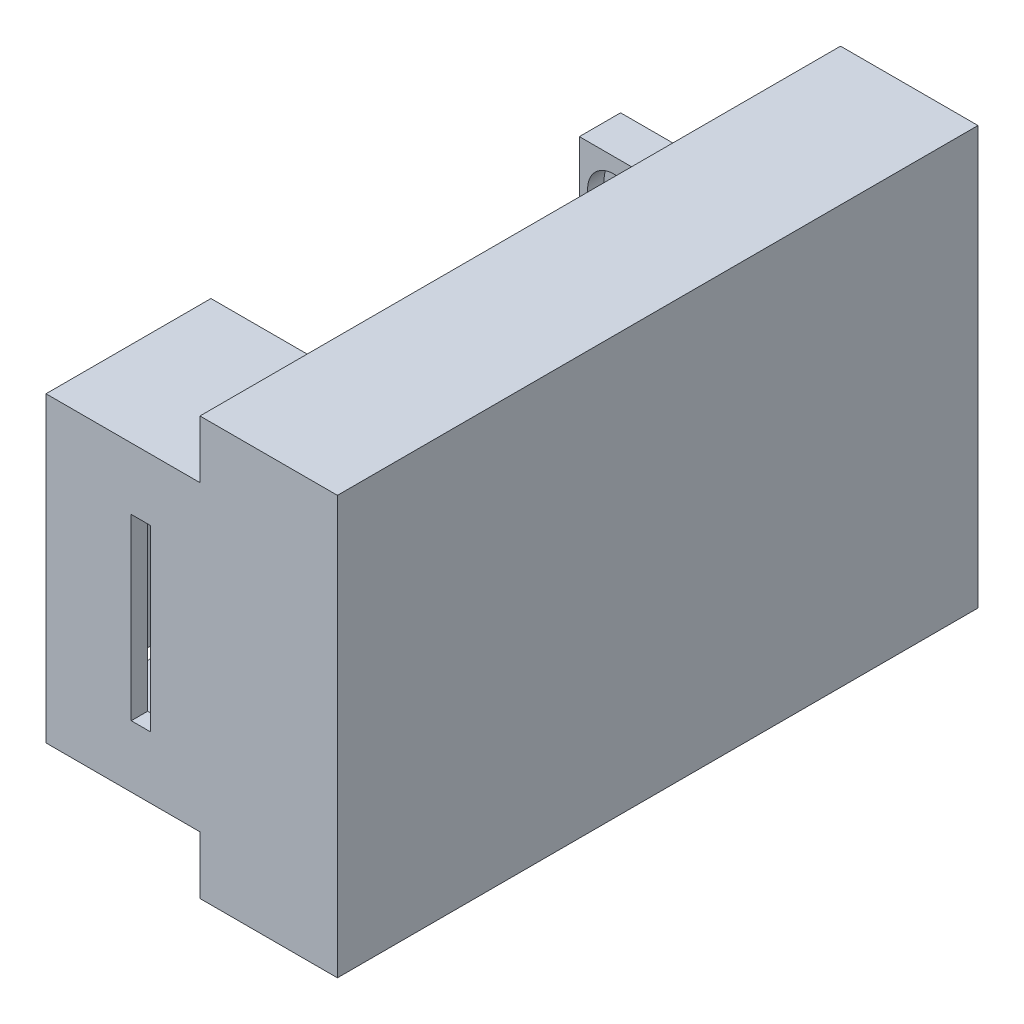
from build123d import *

# Parameters (mm, degrees)
SKETCH1_W                = 238
SKETCH1_H                = 152
SKETCH1_W_2              = 158
SKETCH1_H_2              = 122
BOSS_EXTRUDE1_DEPTH      = 50
SKETCH4_W                = 158
SKETCH4_H                = 122
BOSS_EXTRUDE2_DEPTH      = 10
CUT_EXTRUDE1_START       = -30
SKETCH5_W                = 8
SKETCH5_H                = 132
CUT_EXTRUDE1_DEPTH       = 204
SKETCH8_W                = 25
SKETCH8_H                = 152
CUT_EXTRUDE3_DEPTH       = 50
SKETCH11_W               = 15
SKETCH11_H               = 30
BOSS_EXTRUDE4_DEPTH      = 75
SKETCH16_W               = 15
SKETCH16_H               = 30
BOSS_EXTRUDE6_DEPTH      = 5
SKETCH18_R               = 4
SKETCH18_W               = 8
SKETCH18_H               = 5
CUT_EXTRUDE8_DEPTH       = 7.5
SKETCH19_R               = 2
CUT_EXTRUDE9_DEPTH       = 10
SKETCH20_W               = 50
SKETCH20_H               = 152
BOSS_EXTRUDE7_DEPTH      = 20
SKETCH21_W               = 60
SKETCH21_H               = 110
BOSS_EXTRUDE8_DEPTH      = 56
SKETCH22_W               = 50
SKETCH22_H               = 95
CUT_EXTRUDE10_DEPTH      = 54
SKETCH24_R               = 2.75
CUT_EXTRUDE11_DEPTH      = 1
CUT_EXTRUDE11_DEPTH_BACK = 40
SKETCH25_W               = 7
SKETCH25_H               = 65
CUT_EXTRUDE12_DEPTH      = 12
SKETCH26_W               = 52.5
SKETCH26_H               = 6
CUT_EXTRUDE13_DEPTH      = 40
SKETCH27_W               = 15
SKETCH27_H               = 83
CUT_EXTRUDE14_DEPTH      = 30
SKETCH29_R               = 9.5
CUT_EXTRUDE15_DEPTH      = 6
SKETCH30_R               = 2.5
CUT_EXTRUDE16_DEPTH      = 6
SKETCH34_W               = 45
SKETCH34_H               = 10
CUT_EXTRUDE17_DEPTH      = 10


with BuildPart() as part:
    # Sketch1 → Boss-Extrude1 (new body)
    with BuildSketch(Plane(origin=(0, 0, 0), x_dir=(0, 0, -1), z_dir=(1, 0, 0))):
        Rectangle(SKETCH1_W, SKETCH1_H)
        Rectangle(SKETCH1_W_2, SKETCH1_H_2, mode=Mode.SUBTRACT)
    extrude(amount=BOSS_EXTRUDE1_DEPTH)

    # Sketch4 → Boss-Extrude2 (add)
    with BuildSketch(Plane(origin=(50, 0, 0), x_dir=(0, 0, -1), z_dir=(1, 0, 0))):
        Rectangle(SKETCH4_W, SKETCH4_H)
    extrude(amount=-BOSS_EXTRUDE2_DEPTH)

    # Sketch5 → Cut-Extrude1 (cut)
    with BuildSketch(Plane.XY.offset(119).offset(CUT_EXTRUDE1_START)):
        with Locations((9, 0)):
            Rectangle(SKETCH5_W, SKETCH5_H)
    extrude(amount=-CUT_EXTRUDE1_DEPTH, mode=Mode.SUBTRACT)

    # Sketch8 → Cut-Extrude3 (cut)
    with BuildSketch(Plane.ZY):
        with Locations((-106.5, 0)):
            Rectangle(SKETCH8_W, SKETCH8_H)
    extrude(amount=-CUT_EXTRUDE3_DEPTH, mode=Mode.SUBTRACT)

    # Sketch11 → Boss-Extrude4 (add)
    with BuildSketch(Plane.ZY):
        with Locations((-86.5, 0)):
            Rectangle(SKETCH11_W, SKETCH11_H)
    extrude(amount=BOSS_EXTRUDE4_DEPTH)

    # Sketch16 → Boss-Extrude6 (add)
    with BuildSketch(Plane.ZY.offset(75)):
        with Locations((-86.5, 0)):
            Rectangle(SKETCH16_W, SKETCH16_H)
    extrude(amount=BOSS_EXTRUDE6_DEPTH)

    # Sketch18 → Cut-Extrude8 (cut)
    with BuildSketch(Plane(origin=(0, 0, -94), x_dir=(-1, 0, 0), z_dir=(0, 0, -1))):
        with Locations((-9, 71)):
            Circle(SKETCH18_R)
        with Locations((-9, -71)):
            Circle(SKETCH18_R)
        with Locations((-9, 68.5)):
            Rectangle(SKETCH18_W, SKETCH18_H)
        with Locations((-9, -68.5)):
            Rectangle(SKETCH18_W, SKETCH18_H)
    extrude(amount=-CUT_EXTRUDE8_DEPTH, mode=Mode.SUBTRACT)

    # Sketch19 → Cut-Extrude9 (cut)
    with BuildSketch(Plane(origin=(0, 0, -86.5), x_dir=(-1, 0, 0), z_dir=(0, 0, -1))):
        with Locations((-9, 71)):
            Circle(SKETCH19_R)
        with Locations((-9, -71)):
            Circle(SKETCH19_R)
    extrude(amount=-CUT_EXTRUDE9_DEPTH, mode=Mode.SUBTRACT)

    # Sketch20 → Boss-Extrude7 (add)
    with BuildSketch(Plane.XY.offset(119)):
        with Locations((25, 0)):
            Rectangle(SKETCH20_W, SKETCH20_H)
    extrude(amount=BOSS_EXTRUDE7_DEPTH)

    # Sketch21 → Boss-Extrude8 (add)
    with BuildSketch(Plane.ZY):
        with Locations((109, 0)):
            Rectangle(SKETCH21_W, SKETCH21_H)
    extrude(amount=BOSS_EXTRUDE8_DEPTH)

    # Sketch22 → Cut-Extrude10 (cut)
    with BuildSketch(Plane(origin=(0, 0, 79), x_dir=(-1, 0, 0), z_dir=(0, 0, -1))):
        with Locations((25, 0)):
            Rectangle(SKETCH22_W, SKETCH22_H)
    extrude(amount=-CUT_EXTRUDE10_DEPTH, mode=Mode.SUBTRACT)

    # Sketch24 → Cut-Extrude11 (cut, two sides)
    with BuildSketch(Plane.ZY) as cut_extrude11_sk:
        with Locations((108.6, 36)):
            Circle(SKETCH24_R)
        with Locations((108.6, -36)):
            Circle(SKETCH24_R)
    extrude(amount=CUT_EXTRUDE11_DEPTH, mode=Mode.SUBTRACT)
    extrude(cut_extrude11_sk.sketch, amount=-CUT_EXTRUDE11_DEPTH_BACK, mode=Mode.SUBTRACT)

    # Sketch25 → Cut-Extrude12 (cut)
    with BuildSketch(Plane(origin=(0, 0, 133), x_dir=(-1, 0, 0), z_dir=(0, 0, -1))):
        with Locations((21.5, 0)):
            Rectangle(SKETCH25_W, SKETCH25_H)
    extrude(amount=-CUT_EXTRUDE12_DEPTH, mode=Mode.SUBTRACT)

    # Sketch26 → Cut-Extrude13 (cut)
    with BuildSketch(Plane.ZY):
        with Locations((105.25, 44.5)):
            Rectangle(SKETCH26_W, SKETCH26_H)
        with Locations((105.25, -44.5)):
            Rectangle(SKETCH26_W, SKETCH26_H)
    extrude(amount=-CUT_EXTRUDE13_DEPTH, mode=Mode.SUBTRACT)

    # Sketch27 → Cut-Extrude14 (cut)
    with BuildSketch(Plane.ZY.offset(-13)):
        with Locations((86.5, 0)):
            Rectangle(SKETCH27_W, SKETCH27_H)
    extrude(amount=-CUT_EXTRUDE14_DEPTH, mode=Mode.SUBTRACT)

    # Sketch29 → Cut-Extrude15 (cut)
    with BuildSketch(Plane.XY.offset(-79)):
        with Locations((-67.5, 0)):
            Circle(SKETCH29_R)
    extrude(amount=-CUT_EXTRUDE15_DEPTH, mode=Mode.SUBTRACT)

    # Sketch30 → Cut-Extrude16 (cut)
    with BuildSketch(Plane.ZY.offset(56)):
        with Locations((82.5, 8)):
            Circle(SKETCH30_R)
        with Locations((107.5, 8)):
            Circle(SKETCH30_R)
        with Locations((82.5, 43)):
            Circle(SKETCH30_R)
        with Locations((107.5, 43)):
            Circle(SKETCH30_R)
    extrude(amount=-CUT_EXTRUDE16_DEPTH, mode=Mode.SUBTRACT)

    # Sketch34 → Cut-Extrude17 (cut)
    with BuildSketch(Plane.ZY.offset(56)):
        with Locations((109, -42.5)):
            Rectangle(SKETCH34_W, SKETCH34_H)
    extrude(amount=-CUT_EXTRUDE17_DEPTH, mode=Mode.SUBTRACT)


solid = part.part
